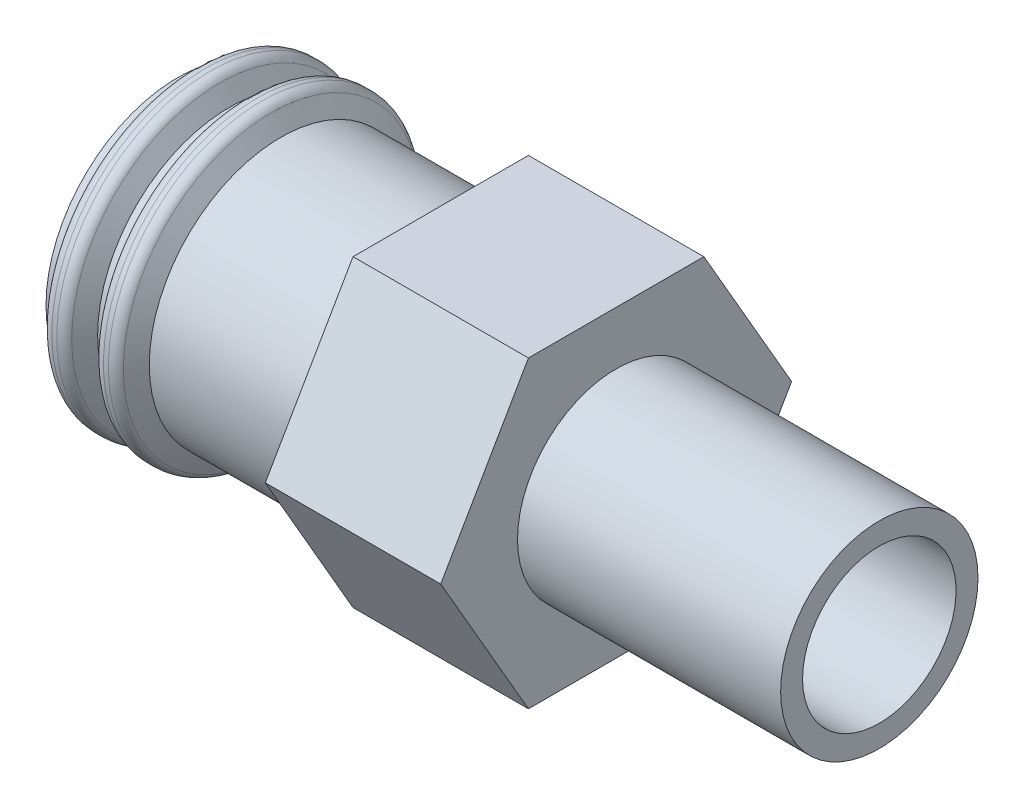
from build123d import *

# Parameters (mm, degrees)
CORTE_EXTRUS_O1_DEPTH = 4
FILETE1_R             = 0.25
FILETE2_R             = 0.25


with BuildPart() as part:
    # Esboço1 → Revolução1 (revolve)
    with BuildSketch(Plane.XY):
        Polygon((-7.322649731, 3), (-7.122649731, 3), (-6.833974596, 3.5), (-6.433974596, 3.5), (-6.145299462, 3), (-2.5, 3), (-2.5, 4), (1.5, 4), (1.5, 2.25), (7.5, 2.25), (7.5, 1.75), (-3.200961894, 1.75), (-4.5, 2.5), (-8.5, 2.5), (-8.5, 3), (-8.3, 3), (-8.011324865, 3.5), (-7.611324865, 3.5), align=None)
    revolve(axis=Axis((-29.721905334, 0, 0), (1, 0, 0)))

    # Esboço2 → Corte-extrusão1 (cut)
    with BuildSketch(Plane(origin=(1.5, 0, 0), x_dir=(0, 0, -1), z_dir=(1, 0, 0))):
        with BuildLine():
            Line((-2, 3.464101615), (2, 3.464101615))
            ThreePointArc((2, 3.464101615), (0, 4), (-2, 3.464101615))
        make_face()
        with BuildLine():
            Line((-4, 0), (-2, 3.464101615))
            ThreePointArc((-2, 3.464101615), (-3.464101615, 2), (-4, 0))
        make_face()
        with BuildLine():
            ThreePointArc((-4, 0), (-3.464101615, -2), (-2, -3.464101615))
            Line((-2, -3.464101615), (-4, 0))
        make_face()
        with BuildLine():
            ThreePointArc((-2, -3.464101615), (0, -4), (2, -3.464101615))
            Line((2, -3.464101615), (-2, -3.464101615))
        make_face()
        with BuildLine():
            ThreePointArc((2, -3.464101615), (3.464101615, -2), (4, 0))
            Line((4, 0), (2, -3.464101615))
        make_face()
        with BuildLine():
            Line((2, 3.464101615), (4, 0))
            ThreePointArc((4, 0), (3.464101615, 2), (2, 3.464101615))
        make_face()
    extrude(amount=-CORTE_EXTRUS_O1_DEPTH, mode=Mode.SUBTRACT)

    # Filete1
    filete1_edges = [part.edges().sort_by_distance(p)[0] for p in [
        (-8.011324865, -3.5, 0),
        (-7.611324865, -3.5, 0),
    ]]
    fillet(filete1_edges, radius=FILETE1_R)

    # Filete2
    filete2_edges = [part.edges().sort_by_distance(p)[0] for p in [
        (-6.833974596, -3.5, 0),
        (-6.433974596, -3.5, 0),
    ]]
    fillet(filete2_edges, radius=FILETE2_R)


solid = part.part
